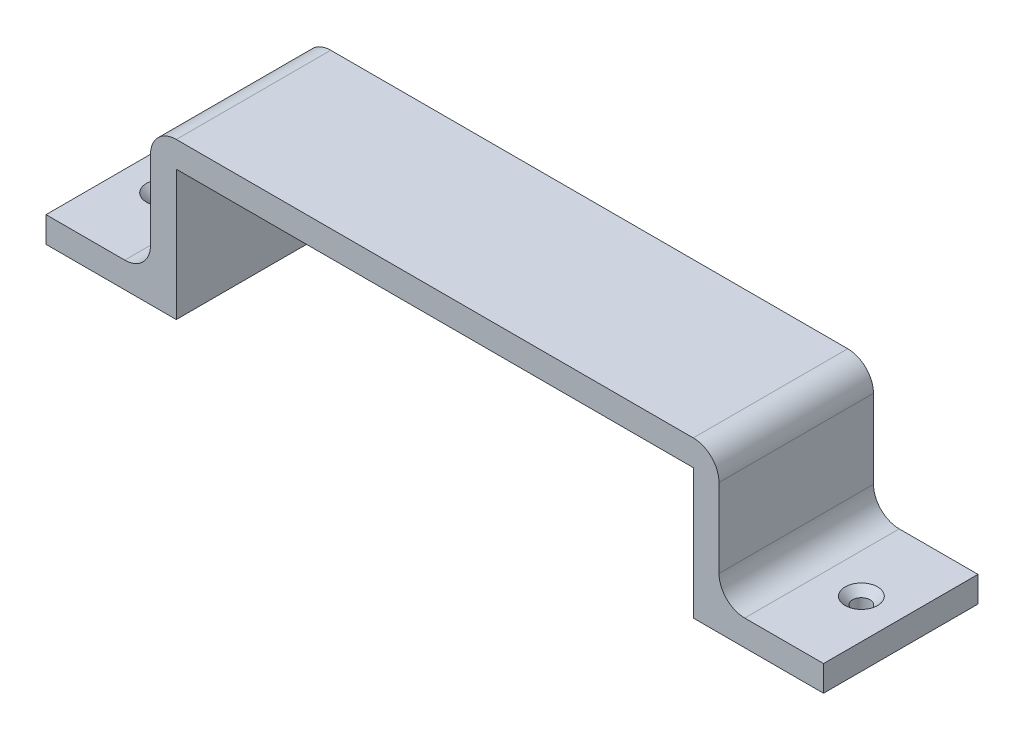
from build123d import *

# Parameters (mm, degrees)
BOSS_EXTRU_1_DEPTH                             = 30
CONG_1_R                                       = 5
FRAISAGE_POUR_VIS_T_TE_FRAIS_E_M31_D           = 3.4
FRAISAGE_POUR_VIS_T_TE_FRAIS_E_M31_CSINK_D     = 6.3
FRAISAGE_POUR_VIS_T_TE_FRAIS_E_M31_CSINK_ANGLE = 90


with BuildPart() as part:
    # Esquisse1 → Boss.-Extru.1 (new body)
    with BuildSketch(Plane.XY):
        Polygon((-50.2, 0), (50.2, 0), (50.2, -25.3), (75.5, -25.3), (75.5, -20.3), (55.2, -20.3), (55.2, 5), (-55.2, 5), (-55.2, -20.3), (-75.5, -20.3), (-75.5, -25.3), (-50.2, -25.3), align=None)
    extrude(amount=BOSS_EXTRU_1_DEPTH)

    # Congé1
    cong_1_edges = [part.edges().sort_by_distance(p)[0] for p in [
        (-55.2, -20.3, 15),
        (-55.2, 5, 15),
        (55.2, 5, 15),
        (55.2, -20.3, 15),
    ]]
    fillet(cong_1_edges, radius=CONG_1_R)

    # Fraisage pour vis à tête fraisée M31 (through all)
    with Locations(Plane(origin=(0, -20.3, 0), x_dir=(1, 0, 0), z_dir=(0, 1, 0))):
        with Locations((-67.85, -15), (67.85, -15)):
            CounterSinkHole(FRAISAGE_POUR_VIS_T_TE_FRAIS_E_M31_D / 2, FRAISAGE_POUR_VIS_T_TE_FRAIS_E_M31_CSINK_D / 2, counter_sink_angle=FRAISAGE_POUR_VIS_T_TE_FRAIS_E_M31_CSINK_ANGLE)


solid = part.part
